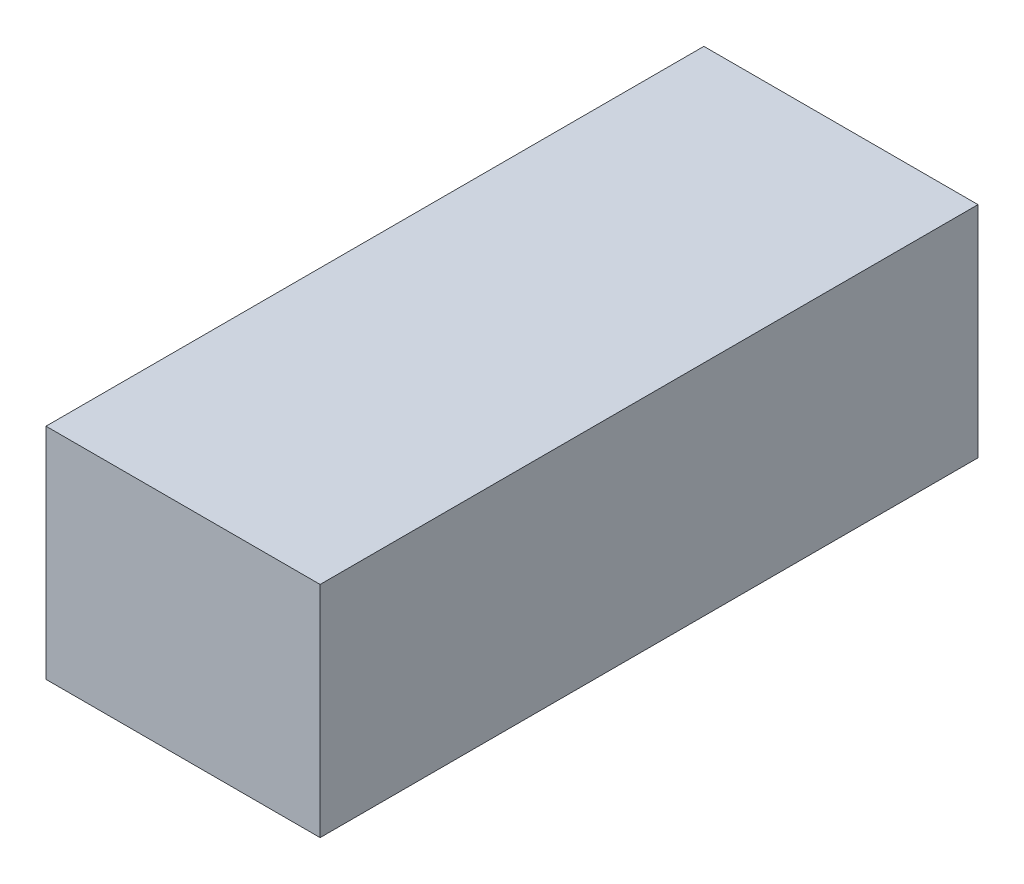
from build123d import *

# Parameters (mm, degrees)
CROQUIS1_W              = 25
CROQUIS1_H              = 20
SALIENTE_EXTRUIR1_DEPTH = 30


with BuildPart() as part:
    # Croquis1 → Saliente-Extruir1 (new body, symmetric)
    with BuildSketch(Plane.XY):
        Rectangle(CROQUIS1_W, CROQUIS1_H)
    extrude(amount=SALIENTE_EXTRUIR1_DEPTH, both=True)


solid = part.part
